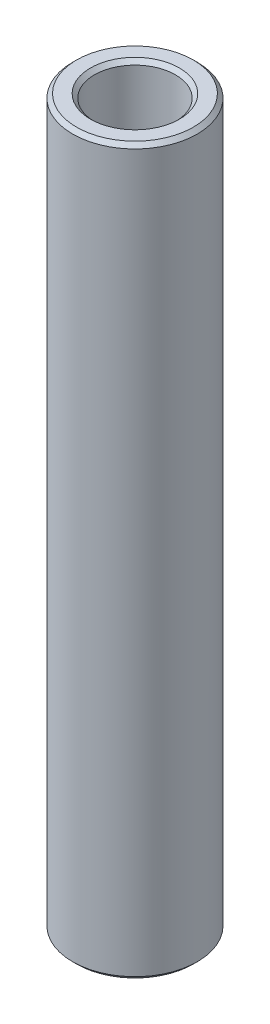
from build123d import *

# Parameters (mm, degrees)
SKETCH1_W     = 0.7
SKETCH1_H     = 23.27402
CHAMFER1_SIZE = 0.127


with BuildPart() as part:
    # Sketch1 → Revolve1 (revolve)
    with BuildSketch(Plane.XY):
        with Locations((1.65, 0)):
            Rectangle(SKETCH1_W, SKETCH1_H)
    revolve(axis=Axis((0, 9.615558323, 0), (0, -1, 0)))

    # Chamfer1
    chamfer1_edges = [part.edges().sort_by_distance(p)[0] for p in [
        (-1.3, 11.63701, 0),
        (-2, 11.63701, 0),
        (-2, -11.63701, 0),
        (-1.3, -11.63701, 0),
    ]]
    chamfer(chamfer1_edges, length=CHAMFER1_SIZE)


solid = part.part
